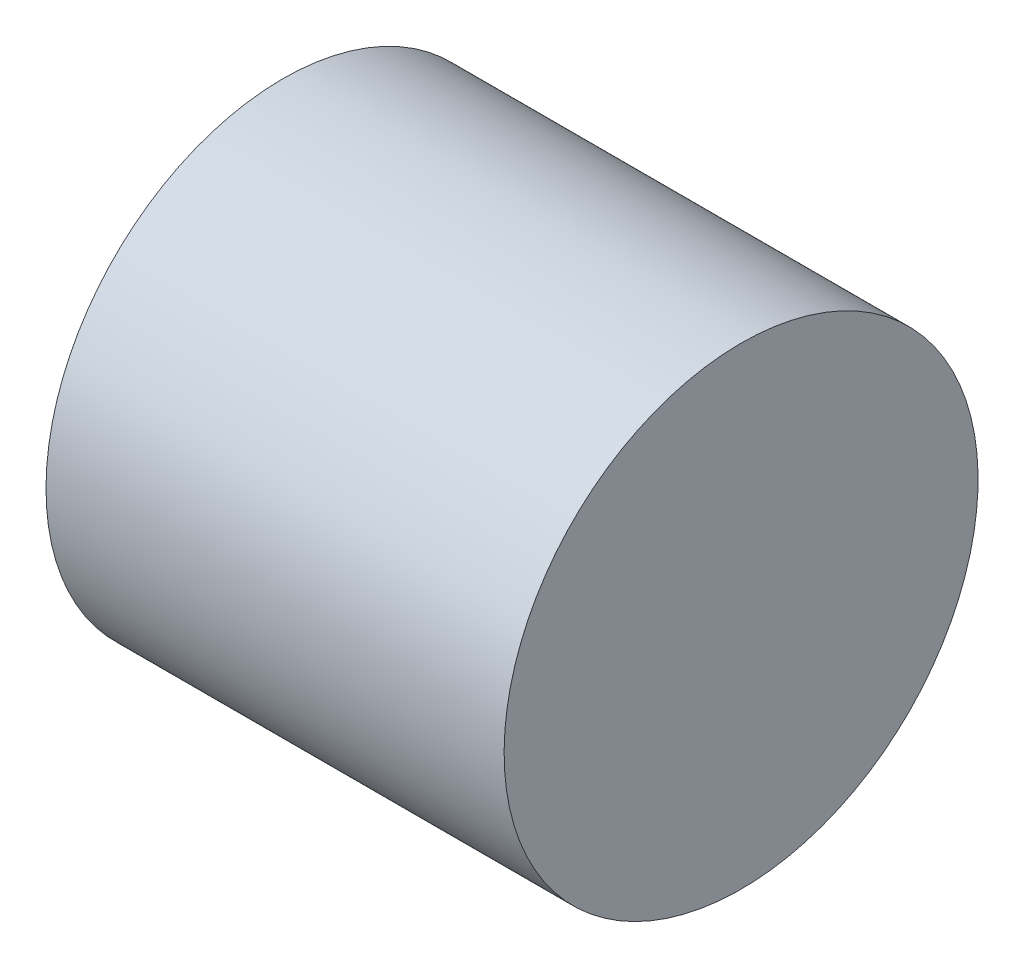
from build123d import *

# Parameters (mm, degrees)
SKETCH1_RX          = 45.986632499
SKETCH1_RY          = 45.891098418
BOSS_EXTRUDE1_DEPTH = 88.9


with BuildPart() as part:
    # Sketch1 → Boss-Extrude1 (new body)
    with BuildSketch(Plane(origin=(0, 0, 0), x_dir=(0, 0, -1), z_dir=(1, 0, 0))):
        with Locations(Location((0, 0), (0, 0, 1.363927532))):
            Ellipse(SKETCH1_RX, SKETCH1_RY)
    extrude(amount=BOSS_EXTRUDE1_DEPTH)


solid = part.part
